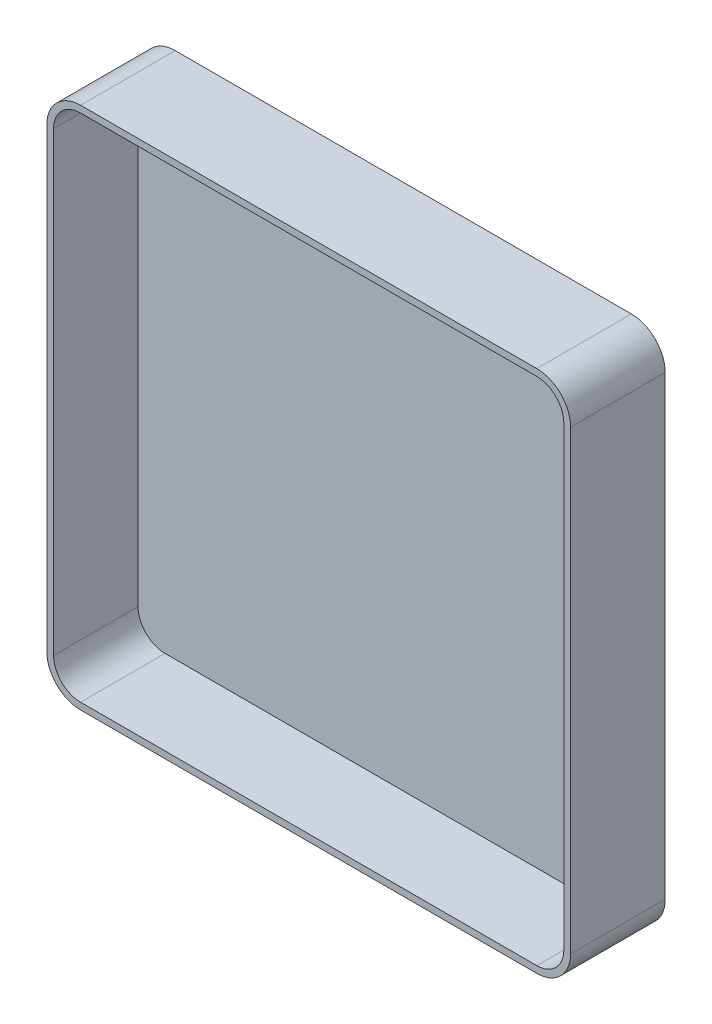
from build123d import *

# Parameters (mm, degrees)
EXTRUDE_1_DEPTH = 3
EXTRUDE_2_DEPTH = 25


with BuildPart() as part:
    # 草图1 → 凸台-拉伸1 (new body)
    with BuildSketch(Plane.XY):
        with BuildLine():
            Line((414.301234579, 12.744075086), (549.301234579, 12.744075086))
            ThreePointArc((549.301234579, 12.744075086), (556.372302391, 15.673007274), (559.301234579, 22.744075086))
            Line((559.301234579, 22.744075086), (559.301234579, 157.744075086))
            ThreePointArc((559.301234579, 157.744075086), (556.372302391, 164.815142898), (549.301234579, 167.744075086))
            Line((549.301234579, 167.744075086), (414.301234579, 167.744075086))
            ThreePointArc((414.301234579, 167.744075086), (407.230166767, 164.815142898), (404.301234579, 157.744075086))
            Line((404.301234579, 157.744075086), (404.301234579, 22.744075086))
            ThreePointArc((404.301234579, 22.744075086), (407.230166767, 15.673007274), (414.301234579, 12.744075086))
        make_face()
    extrude(amount=EXTRUDE_1_DEPTH)

    # 草图2 → 凸台-拉伸2 (add)
    with BuildSketch(Plane.XY.offset(3)):
        with BuildLine():
            Line((414.301234579, 12.744075086), (549.301234579, 12.744075086))
            ThreePointArc((549.301234579, 12.744075086), (556.372302391, 15.673007274), (559.301234579, 22.744075086))
            Line((559.301234579, 22.744075086), (559.301234579, 157.744075086))
            ThreePointArc((559.301234579, 157.744075086), (556.372302391, 164.815142898), (549.301234579, 167.744075086))
            Line((549.301234579, 167.744075086), (414.301234579, 167.744075086))
            ThreePointArc((414.301234579, 167.744075086), (407.230166767, 164.815142898), (404.301234579, 157.744075086))
            Line((404.301234579, 157.744075086), (404.301234579, 22.744075086))
            ThreePointArc((404.301234579, 22.744075086), (407.230166767, 15.673007274), (414.301234579, 12.744075086))
        make_face()
        with BuildLine():
            Line((557.301234579, 22.744075086), (557.301234579, 157.744075086))
            ThreePointArc((557.301234579, 157.744075086), (554.958088829, 163.400929335), (549.301234579, 165.744075086))
            Line((549.301234579, 165.744075086), (414.301234579, 165.744075086))
            ThreePointArc((414.301234579, 165.744075086), (408.64438033, 163.400929335), (406.301234579, 157.744075086))
            Line((406.301234579, 157.744075086), (406.301234579, 22.744075086))
            ThreePointArc((406.301234579, 22.744075086), (408.64438033, 17.087220836), (414.301234579, 14.744075086))
            Line((414.301234579, 14.744075086), (549.301234579, 14.744075086))
            ThreePointArc((549.301234579, 14.744075086), (554.958088829, 17.087220836), (557.301234579, 22.744075086))
        make_face(mode=Mode.SUBTRACT)
    extrude(amount=EXTRUDE_2_DEPTH)


solid = part.part
